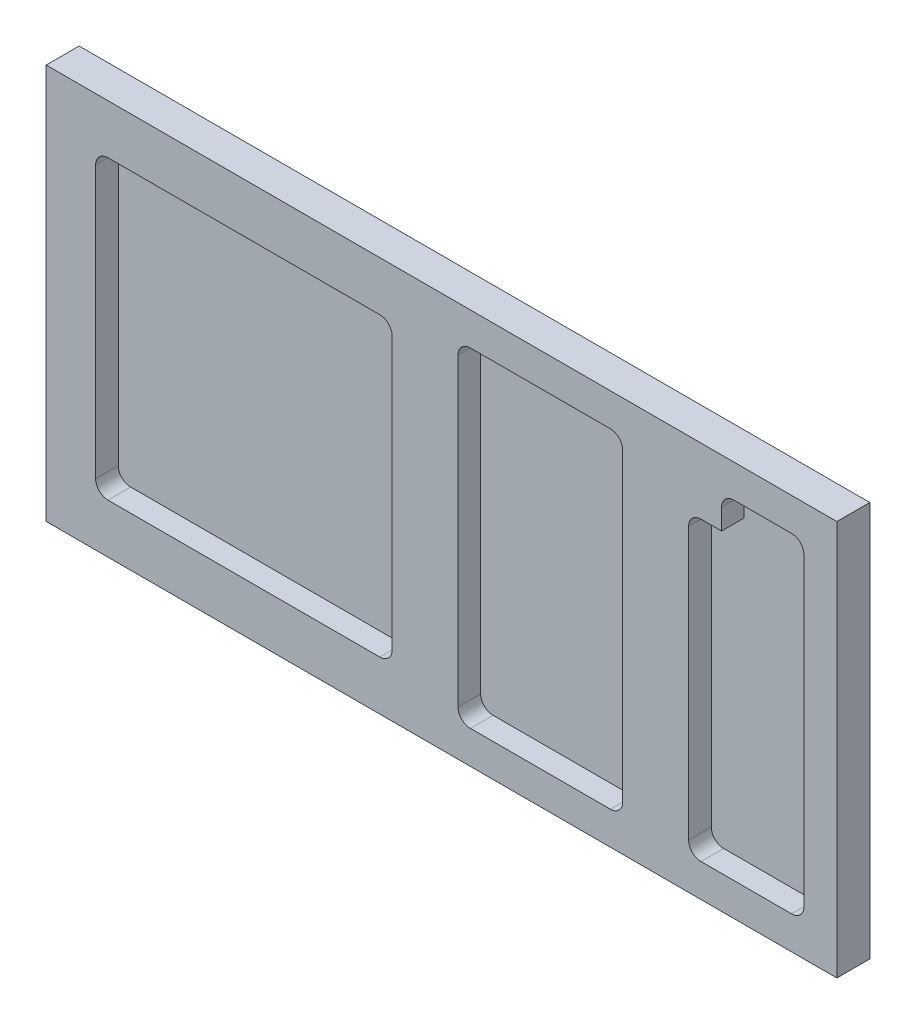
from build123d import *

# Parameters (mm, degrees)
SKETCH1_W           = 304.8
SKETCH1_H           = 152.4
BOSS_EXTRUDE1_DEPTH = 12.7
CUT_EXTRUDE1_DEPTH  = 8.73252
CUT_EXTRUDE2_DEPTH  = 8.73252


with BuildPart() as part:
    # Sketch1 → Boss-Extrude1 (new body)
    with BuildSketch(Plane.XY):
        Rectangle(SKETCH1_W, SKETCH1_H)
    extrude(amount=BOSS_EXTRUDE1_DEPTH)

    # Sketch2 → Cut-Extrude1 (cut)
    with BuildSketch(Plane.XY.offset(12.7)):
        with BuildLine():
            Line((-128.5875, 57.15), (-23.8125, 57.15))
            ThreePointArc((-23.8125, 57.15), (-20.444903955, 55.755096045), (-19.05, 52.3875))
            Line((-19.05, 52.3875), (-19.05, -52.3875))
            ThreePointArc((-19.05, -52.3875), (-20.444903955, -55.755096045), (-23.8125, -57.15))
            Line((-23.8125, -57.15), (-128.5875, -57.15))
            ThreePointArc((-128.5875, -57.15), (-131.955096045, -55.755096045), (-133.35, -52.3875))
            Line((-133.35, -52.3875), (-133.35, 52.3875))
            ThreePointArc((-133.35, 52.3875), (-131.955096045, 55.755096045), (-128.5875, 57.15))
        make_face()
    extrude(amount=-CUT_EXTRUDE1_DEPTH, mode=Mode.SUBTRACT)

    # Sketch3 → Cut-Extrude2 (cut)
    with BuildSketch(Plane.XY.offset(12.7)):
        with BuildLine():
            Line((100.0125, 50.8), (107.95, 50.8))
            Line((107.95, 50.8), (107.95, 58.7375))
            ThreePointArc((107.95, 58.7375), (109.344903955, 62.105096045), (112.7125, 63.5))
            Line((112.7125, 63.5), (134.9375, 63.5))
            ThreePointArc((134.9375, 63.5), (138.305096045, 62.105096045), (139.7, 58.7375))
            Line((139.7, 58.7375), (139.7, 50.8))
            Line((139.7, 50.8), (139.7, -58.7375))
            ThreePointArc((139.7, -58.7375), (138.305096045, -62.105096045), (134.9375, -63.5))
            Line((134.9375, -63.5), (100.0125, -63.5))
            ThreePointArc((100.0125, -63.5), (96.644903955, -62.105096045), (95.25, -58.7375))
            Line((95.25, -58.7375), (95.25, 46.0375))
            ThreePointArc((95.25, 46.0375), (96.644903955, 49.405096045), (100.0125, 50.8))
        make_face()
        with BuildLine():
            Line((11.1125, 63.5), (65.0875, 63.5))
            ThreePointArc((65.0875, 63.5), (68.455096045, 62.105096045), (69.85, 58.7375))
            Line((69.85, 58.7375), (69.85, -58.7375))
            ThreePointArc((69.85, -58.7375), (68.455096045, -62.105096045), (65.0875, -63.5))
            Line((65.0875, -63.5), (11.1125, -63.5))
            ThreePointArc((11.1125, -63.5), (7.744903955, -62.105096045), (6.35, -58.7375))
            Line((6.35, -58.7375), (6.35, 58.7375))
            ThreePointArc((6.35, 58.7375), (7.744903955, 62.105096045), (11.1125, 63.5))
        make_face()
    extrude(amount=-CUT_EXTRUDE2_DEPTH, mode=Mode.SUBTRACT)


solid = part.part
